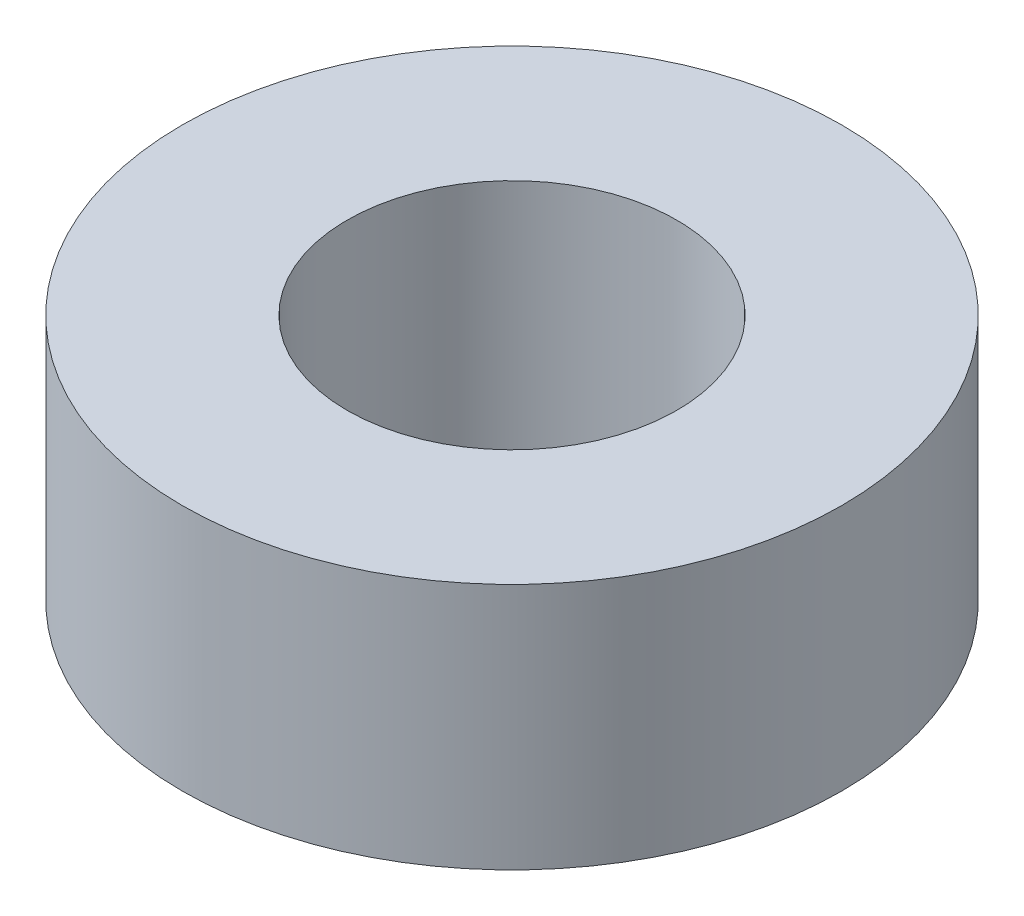
from build123d import *

# Parameters (mm, degrees)
SKETCH2_R           = 4
BOSS_EXTRUDE1_DEPTH = 3
SKETCH3_R           = 2
CUT_EXTRUDE1_DEPTH  = 3


with BuildPart() as part:
    # Sketch2 → Boss-Extrude1 (new body)
    with BuildSketch(Plane(origin=(0, 0, 0), x_dir=(1, 0, 0), z_dir=(0, 1, 0))):
        Circle(SKETCH2_R)
    extrude(amount=BOSS_EXTRUDE1_DEPTH)

    # Sketch3 → Cut-Extrude1 (cut)
    with BuildSketch(Plane(origin=(0, 0, 0), x_dir=(1, 0, 0), z_dir=(0, 1, 0))):
        Circle(SKETCH3_R)
    extrude(amount=CUT_EXTRUDE1_DEPTH, mode=Mode.SUBTRACT)


solid = part.part
